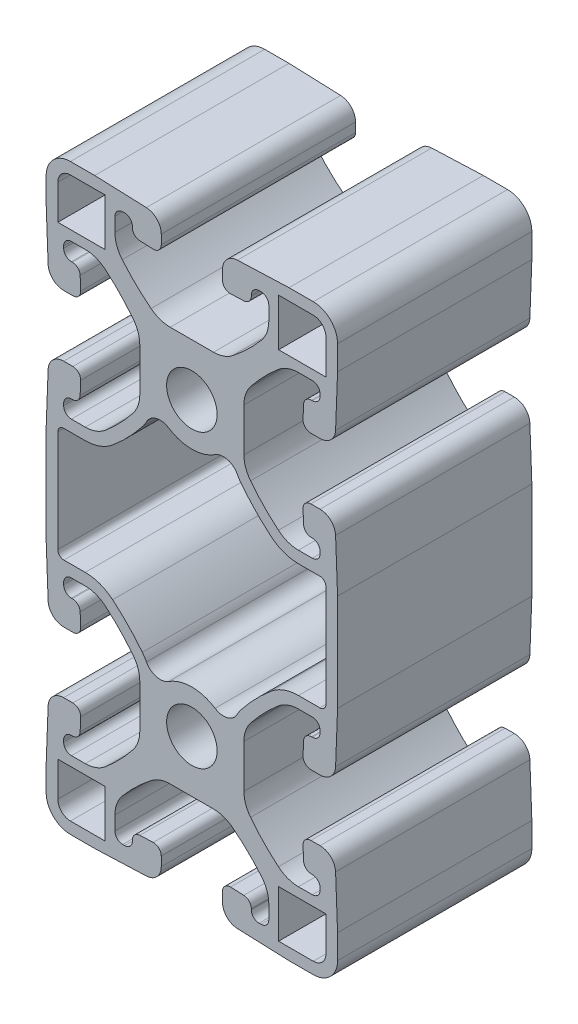
from build123d import *

# Parameters (mm, degrees)
SKETCH1_R      = 3.302
EXTRUDE1_DEPTH = 25.4


with BuildPart() as part:
    # Sketch1 → Extrude1 (new body)
    with BuildSketch(Plane.XY):
        with BuildLine():
            Line((6.8072, 35.271899209), (6.8072, 40.928100791))
            ThreePointArc((6.8072, 40.928100791), (7.029801128, 42.254656747), (7.673219048, 43.435891418))
            ThreePointArc((7.673219048, 43.435891418), (9.397406099, 45.414841404), (11.316608824, 47.205295238))
            ThreePointArc((11.316608824, 47.205295238), (12.53999053, 47.912696364), (13.931647412, 48.1584))
            Line((13.931647412, 48.1584), (15.748, 48.1584))
            ThreePointArc((15.748, 48.1584), (16.46642049, 47.86082049), (16.764, 47.1424))
            Line((16.764, 47.1424), (16.764, 46.8884))
            ThreePointArc((16.764, 46.8884), (16.46642049, 46.16997951), (15.748, 45.8724))
            Line((15.748, 45.8724), (15.618909217, 45.8724))
            ThreePointArc((15.618909217, 45.8724), (14.91441296, 45.588479929), (14.603658094, 44.895402014))
            Line((14.603658094, 44.895402014), (14.536817878, 43.155502014))
            ThreePointArc((14.536817878, 43.155502014), (14.819989072, 42.412003742), (15.552069001, 42.1005))
            Line((15.552069001, 42.1005), (16.760361628, 42.1005))
            ThreePointArc((16.760361628, 42.1005), (18.169354143, 42.668340141), (18.790863874, 44.054495972))
            Line((18.790863874, 44.054495972), (19.05, 50.8))
            Line((19.05, 50.8), (19.05, 53.975))
            ThreePointArc((19.05, 53.975), (18.12006403, 56.22006403), (15.875, 57.15))
            Line((15.875, 57.15), (12.7, 57.15))
            Line((12.7, 57.15), (5.954495972, 56.890863874))
            ThreePointArc((5.954495972, 56.890863874), (4.568340141, 56.269354143), (4.0005, 54.860361628))
            Line((4.0005, 54.860361628), (4.0005, 53.652069001))
            ThreePointArc((4.0005, 53.652069001), (4.312003742, 52.919989072), (5.055502014, 52.636817878))
            Line((5.055502014, 52.636817878), (6.795402014, 52.703658094))
            ThreePointArc((6.795402014, 52.703658094), (7.488479929, 53.01441296), (7.7724, 53.718909217))
            Line((7.7724, 53.718909217), (7.7724, 53.848))
            ThreePointArc((7.7724, 53.848), (8.06997951, 54.56642049), (8.7884, 54.864))
            Line((8.7884, 54.864), (9.0424, 54.864))
            ThreePointArc((9.0424, 54.864), (9.76082049, 54.56642049), (10.0584, 53.848))
            Line((10.0584, 53.848), (10.0584, 52.031647412))
            ThreePointArc((10.0584, 52.031647412), (9.812696364, 50.63999053), (9.105295238, 49.416608824))
            ThreePointArc((9.105295238, 49.416608824), (7.314841404, 47.497406099), (5.335891418, 45.773219048))
            ThreePointArc((5.335891418, 45.773219048), (4.154656747, 45.129801128), (2.828100791, 44.9072))
            Line((2.828100791, 44.9072), (-2.828100791, 44.9072))
            ThreePointArc((-2.828100791, 44.9072), (-4.154656747, 45.129801128), (-5.335891418, 45.773219048))
            ThreePointArc((-5.335891418, 45.773219048), (-7.314841404, 47.497406099), (-9.105295238, 49.416608824))
            ThreePointArc((-9.105295238, 49.416608824), (-9.812696364, 50.63999053), (-10.0584, 52.031647412))
            Line((-10.0584, 52.031647412), (-10.0584, 53.848))
            ThreePointArc((-10.0584, 53.848), (-9.76082049, 54.56642049), (-9.0424, 54.864))
            Line((-9.0424, 54.864), (-8.7884, 54.864))
            ThreePointArc((-8.7884, 54.864), (-8.06997951, 54.56642049), (-7.7724, 53.848))
            Line((-7.7724, 53.848), (-7.7724, 53.718909217))
            ThreePointArc((-7.7724, 53.718909217), (-7.488479929, 53.01441296), (-6.795402014, 52.703658094))
            Line((-6.795402014, 52.703658094), (-5.055502014, 52.636817878))
            ThreePointArc((-5.055502014, 52.636817878), (-4.312003742, 52.919989072), (-4.0005, 53.652069001))
            Line((-4.0005, 53.652069001), (-4.0005, 54.860361628))
            ThreePointArc((-4.0005, 54.860361628), (-4.568340141, 56.269354143), (-5.954495972, 56.890863874))
            Line((-5.954495972, 56.890863874), (-12.7, 57.15))
            Line((-12.7, 57.15), (-15.875, 57.15))
            ThreePointArc((-15.875, 57.15), (-18.12006403, 56.22006403), (-19.05, 53.975))
            Line((-19.05, 53.975), (-19.05, 50.8))
            Line((-19.05, 50.8), (-18.790863874, 44.054495972))
            ThreePointArc((-18.790863874, 44.054495972), (-18.169354143, 42.668340141), (-16.760361628, 42.1005))
            Line((-16.760361628, 42.1005), (-15.552069001, 42.1005))
            ThreePointArc((-15.552069001, 42.1005), (-14.819989072, 42.412003742), (-14.536817878, 43.155502014))
            Line((-14.536817878, 43.155502014), (-14.603658094, 44.895402014))
            ThreePointArc((-14.603658094, 44.895402014), (-14.91441296, 45.588479929), (-15.618909217, 45.8724))
            Line((-15.618909217, 45.8724), (-15.748, 45.8724))
            ThreePointArc((-15.748, 45.8724), (-16.46642049, 46.16997951), (-16.764, 46.8884))
            Line((-16.764, 46.8884), (-16.764, 47.1424))
            ThreePointArc((-16.764, 47.1424), (-16.46642049, 47.86082049), (-15.748, 48.1584))
            Line((-15.748, 48.1584), (-13.931647412, 48.1584))
            ThreePointArc((-13.931647412, 48.1584), (-12.53999053, 47.912696364), (-11.316608824, 47.205295238))
            ThreePointArc((-11.316608824, 47.205295238), (-9.397406099, 45.414841404), (-7.673219048, 43.435891418))
            ThreePointArc((-7.673219048, 43.435891418), (-7.029801128, 42.254656747), (-6.8072, 40.928100791))
            Line((-6.8072, 40.928100791), (-6.8072, 35.271899209))
            ThreePointArc((-6.8072, 35.271899209), (-7.029801128, 33.945343253), (-7.673219048, 32.764108582))
            ThreePointArc((-7.673219048, 32.764108582), (-9.397406099, 30.785158596), (-11.316608824, 28.994704762))
            ThreePointArc((-11.316608824, 28.994704762), (-12.53999053, 28.287303636), (-13.931647412, 28.0416))
            Line((-13.931647412, 28.0416), (-15.748, 28.0416))
            ThreePointArc((-15.748, 28.0416), (-16.46642049, 28.33917951), (-16.764, 29.0576))
            Line((-16.764, 29.0576), (-16.764, 29.3116))
            ThreePointArc((-16.764, 29.3116), (-16.46642049, 30.03002049), (-15.748, 30.3276))
            Line((-15.748, 30.3276), (-15.618909217, 30.3276))
            ThreePointArc((-15.618909217, 30.3276), (-14.91441296, 30.611520071), (-14.603658094, 31.304597986))
            Line((-14.603658094, 31.304597986), (-14.536817878, 33.044497986))
            ThreePointArc((-14.536817878, 33.044497986), (-14.819989072, 33.787996258), (-15.552069001, 34.0995))
            Line((-15.552069001, 34.0995), (-16.760361628, 34.0995))
            ThreePointArc((-16.760361628, 34.0995), (-18.169354143, 33.531659859), (-18.790863874, 32.145504028))
            Line((-18.790863874, 32.145504028), (-19.05, 25.4))
            Line((-19.05, 25.4), (-19.05, 12.7))
            Line((-19.05, 12.7), (-18.790863874, 5.954495972))
            ThreePointArc((-18.790863874, 5.954495972), (-18.169354143, 4.568340141), (-16.760361628, 4.0005))
            Line((-16.760361628, 4.0005), (-15.552069001, 4.0005))
            ThreePointArc((-15.552069001, 4.0005), (-14.819989072, 4.312003742), (-14.536817878, 5.055502014))
            Line((-14.536817878, 5.055502014), (-14.603658094, 6.795402014))
            ThreePointArc((-14.603658094, 6.795402014), (-14.91441296, 7.488479929), (-15.618909217, 7.7724))
            Line((-15.618909217, 7.7724), (-15.748, 7.7724))
            ThreePointArc((-15.748, 7.7724), (-16.46642049, 8.06997951), (-16.764, 8.7884))
            Line((-16.764, 8.7884), (-16.764, 9.0424))
            ThreePointArc((-16.764, 9.0424), (-16.46642049, 9.76082049), (-15.748, 10.0584))
            Line((-15.748, 10.0584), (-13.931647412, 10.0584))
            ThreePointArc((-13.931647412, 10.0584), (-12.53999053, 9.812696364), (-11.316608824, 9.105295238))
            ThreePointArc((-11.316608824, 9.105295238), (-9.397406099, 7.314841404), (-7.673219048, 5.335891418))
            ThreePointArc((-7.673219048, 5.335891418), (-7.029801128, 4.154656747), (-6.8072, 2.828100791))
            Line((-6.8072, 2.828100791), (-6.8072, -2.828100791))
            ThreePointArc((-6.8072, -2.828100791), (-7.029801128, -4.154656747), (-7.673219048, -5.335891418))
            ThreePointArc((-7.673219048, -5.335891418), (-9.397406099, -7.314841404), (-11.316608824, -9.105295238))
            ThreePointArc((-11.316608824, -9.105295238), (-12.53999053, -9.812696364), (-13.931647412, -10.0584))
            Line((-13.931647412, -10.0584), (-15.748, -10.0584))
            ThreePointArc((-15.748, -10.0584), (-16.46642049, -9.76082049), (-16.764, -9.0424))
            Line((-16.764, -9.0424), (-16.764, -8.7884))
            ThreePointArc((-16.764, -8.7884), (-16.46642049, -8.06997951), (-15.748, -7.7724))
            Line((-15.748, -7.7724), (-15.618909217, -7.7724))
            ThreePointArc((-15.618909217, -7.7724), (-14.91441296, -7.488479929), (-14.603658094, -6.795402014))
            Line((-14.603658094, -6.795402014), (-14.536817878, -5.055502014))
            ThreePointArc((-14.536817878, -5.055502014), (-14.819989072, -4.312003742), (-15.552069001, -4.0005))
            Line((-15.552069001, -4.0005), (-16.760361628, -4.0005))
            ThreePointArc((-16.760361628, -4.0005), (-18.169354143, -4.568340141), (-18.790863874, -5.954495972))
            Line((-18.790863874, -5.954495972), (-19.05, -12.7))
            Line((-19.05, -12.7), (-19.05, -15.875))
            ThreePointArc((-19.05, -15.875), (-18.12006403, -18.12006403), (-15.875, -19.05))
            Line((-15.875, -19.05), (-12.7, -19.05))
            Line((-12.7, -19.05), (-5.954495972, -18.790863874))
            ThreePointArc((-5.954495972, -18.790863874), (-4.568340141, -18.169354143), (-4.0005, -16.760361628))
            Line((-4.0005, -16.760361628), (-4.0005, -15.552069001))
            ThreePointArc((-4.0005, -15.552069001), (-4.312003742, -14.819989072), (-5.055502014, -14.536817878))
            Line((-5.055502014, -14.536817878), (-6.795402014, -14.603658094))
            ThreePointArc((-6.795402014, -14.603658094), (-7.488479929, -14.91441296), (-7.7724, -15.618909217))
            Line((-7.7724, -15.618909217), (-7.7724, -15.748))
            ThreePointArc((-7.7724, -15.748), (-8.06997951, -16.46642049), (-8.7884, -16.764))
            Line((-8.7884, -16.764), (-9.0424, -16.764))
            ThreePointArc((-9.0424, -16.764), (-9.76082049, -16.46642049), (-10.0584, -15.748))
            Line((-10.0584, -15.748), (-10.0584, -13.931647412))
            ThreePointArc((-10.0584, -13.931647412), (-9.812696364, -12.53999053), (-9.105295238, -11.316608824))
            ThreePointArc((-9.105295238, -11.316608824), (-7.314841404, -9.397406099), (-5.335891418, -7.673219048))
            ThreePointArc((-5.335891418, -7.673219048), (-4.154656747, -7.029801128), (-2.828100791, -6.8072))
            Line((-2.828100791, -6.8072), (2.828100791, -6.8072))
            ThreePointArc((2.828100791, -6.8072), (4.154656747, -7.029801128), (5.335891418, -7.673219048))
            ThreePointArc((5.335891418, -7.673219048), (7.314841404, -9.397406099), (9.105295238, -11.316608824))
            ThreePointArc((9.105295238, -11.316608824), (9.812696364, -12.53999053), (10.0584, -13.931647412))
            Line((10.0584, -13.931647412), (10.0584, -15.748))
            ThreePointArc((10.0584, -15.748), (9.76082049, -16.46642049), (9.0424, -16.764))
            Line((9.0424, -16.764), (8.7884, -16.764))
            ThreePointArc((8.7884, -16.764), (8.06997951, -16.46642049), (7.7724, -15.748))
            Line((7.7724, -15.748), (7.7724, -15.618909217))
            ThreePointArc((7.7724, -15.618909217), (7.488479929, -14.91441296), (6.795402014, -14.603658094))
            Line((6.795402014, -14.603658094), (5.055502014, -14.536817878))
            ThreePointArc((5.055502014, -14.536817878), (4.312003742, -14.819989072), (4.0005, -15.552069001))
            Line((4.0005, -15.552069001), (4.0005, -16.760361628))
            ThreePointArc((4.0005, -16.760361628), (4.568340141, -18.169354143), (5.954495972, -18.790863874))
            Line((5.954495972, -18.790863874), (12.7, -19.05))
            Line((12.7, -19.05), (15.875, -19.05))
            ThreePointArc((15.875, -19.05), (18.12006403, -18.12006403), (19.05, -15.875))
            Line((19.05, -15.875), (19.05, -12.7))
            Line((19.05, -12.7), (18.790863874, -5.954495972))
            ThreePointArc((18.790863874, -5.954495972), (18.169354143, -4.568340141), (16.760361628, -4.0005))
            Line((16.760361628, -4.0005), (15.552069001, -4.0005))
            ThreePointArc((15.552069001, -4.0005), (14.819989072, -4.312003742), (14.536817878, -5.055502014))
            Line((14.536817878, -5.055502014), (14.603658094, -6.795402014))
            ThreePointArc((14.603658094, -6.795402014), (14.91441296, -7.488479929), (15.618909217, -7.7724))
            Line((15.618909217, -7.7724), (15.748, -7.7724))
            ThreePointArc((15.748, -7.7724), (16.46642049, -8.06997951), (16.764, -8.7884))
            Line((16.764, -8.7884), (16.764, -9.0424))
            ThreePointArc((16.764, -9.0424), (16.46642049, -9.76082049), (15.748, -10.0584))
            Line((15.748, -10.0584), (13.931647412, -10.0584))
            ThreePointArc((13.931647412, -10.0584), (12.53999053, -9.812696364), (11.316608824, -9.105295238))
            ThreePointArc((11.316608824, -9.105295238), (9.397406099, -7.314841404), (7.673219048, -5.335891418))
            ThreePointArc((7.673219048, -5.335891418), (7.029801128, -4.154656747), (6.8072, -2.828100791))
            Line((6.8072, -2.828100791), (6.8072, 2.828100791))
            ThreePointArc((6.8072, 2.828100791), (7.029801128, 4.154656747), (7.673219048, 5.335891418))
            ThreePointArc((7.673219048, 5.335891418), (9.397406099, 7.314841404), (11.316608824, 9.105295238))
            ThreePointArc((11.316608824, 9.105295238), (12.53999053, 9.812696364), (13.931647412, 10.0584))
            Line((13.931647412, 10.0584), (15.748, 10.0584))
            ThreePointArc((15.748, 10.0584), (16.46642049, 9.76082049), (16.764, 9.0424))
            Line((16.764, 9.0424), (16.764, 8.7884))
            ThreePointArc((16.764, 8.7884), (16.46642049, 8.06997951), (15.748, 7.7724))
            Line((15.748, 7.7724), (15.618909217, 7.7724))
            ThreePointArc((15.618909217, 7.7724), (14.91441296, 7.488479929), (14.603658094, 6.795402014))
            Line((14.603658094, 6.795402014), (14.536817878, 5.055502014))
            ThreePointArc((14.536817878, 5.055502014), (14.819989072, 4.312003742), (15.552069001, 4.0005))
            Line((15.552069001, 4.0005), (16.760361628, 4.0005))
            ThreePointArc((16.760361628, 4.0005), (18.169354143, 4.568340141), (18.790863874, 5.954495972))
            Line((18.790863874, 5.954495972), (19.05, 12.7))
            Line((19.05, 12.7), (19.05, 25.4))
            Line((19.05, 25.4), (18.790863874, 32.145504028))
            ThreePointArc((18.790863874, 32.145504028), (18.169354143, 33.531659859), (16.760361628, 34.0995))
            Line((16.760361628, 34.0995), (15.552069001, 34.0995))
            ThreePointArc((15.552069001, 34.0995), (14.819989072, 33.787996258), (14.536817878, 33.044497986))
            Line((14.536817878, 33.044497986), (14.603658094, 31.304597986))
            ThreePointArc((14.603658094, 31.304597986), (14.91441296, 30.611520071), (15.618909217, 30.3276))
            Line((15.618909217, 30.3276), (15.748, 30.3276))
            ThreePointArc((15.748, 30.3276), (16.46642049, 30.03002049), (16.764, 29.3116))
            Line((16.764, 29.3116), (16.764, 29.0576))
            ThreePointArc((16.764, 29.0576), (16.46642049, 28.33917951), (15.748, 28.0416))
            Line((15.748, 28.0416), (13.931647412, 28.0416))
            ThreePointArc((13.931647412, 28.0416), (12.53999053, 28.287303636), (11.316608824, 28.994704762))
            ThreePointArc((11.316608824, 28.994704762), (9.397406099, 30.785158596), (7.673219048, 32.764108582))
            ThreePointArc((7.673219048, 32.764108582), (7.029801128, 33.945343253), (6.8072, 35.271899209))
        make_face()
        Circle(SKETCH1_R, mode=Mode.SUBTRACT)
        with Locations((0, 38.1)):
            Circle(SKETCH1_R, mode=Mode.SUBTRACT)
        with BuildLine():
            Line((13.946769755, 26.5049), (16.73225, 26.5049))
            ThreePointArc((16.73225, 26.5049), (17.293516008, 26.272416008), (17.526, 25.71115))
            Line((17.526, 25.71115), (17.526, 12.38885))
            ThreePointArc((17.526, 12.38885), (17.293516008, 11.827583992), (16.73225, 11.5951))
            Line((16.73225, 11.5951), (13.946769755, 11.5951))
            ThreePointArc((13.946769755, 11.5951), (12.035671421, 11.258142483), (10.35505231, 10.287907143))
            ThreePointArc((10.35505231, 10.287907143), (8.310276003, 8.382956855), (6.47397619, 6.276312903))
            ThreePointArc((6.47397619, 6.276312903), (6.185713688, 5.873090449), (5.934316511, 5.445910069))
            ThreePointArc((5.934316511, 5.445910069), (4.65067534, 4.431295394), (3.035329845, 4.691749859))
            ThreePointArc((3.035329845, 4.691749859), (0, 5.588), (-3.035329845, 4.691749859))
            ThreePointArc((-3.035329845, 4.691749859), (-4.65067534, 4.431295394), (-5.934316511, 5.445910069))
            ThreePointArc((-5.934316511, 5.445910069), (-6.185713688, 5.873090449), (-6.47397619, 6.276312903))
            ThreePointArc((-6.47397619, 6.276312903), (-8.310276003, 8.382956855), (-10.35505231, 10.287907143))
            ThreePointArc((-10.35505231, 10.287907143), (-12.035671421, 11.258142483), (-13.946769755, 11.5951))
            Line((-13.946769755, 11.5951), (-16.73225, 11.5951))
            ThreePointArc((-16.73225, 11.5951), (-17.293516008, 11.827583992), (-17.526, 12.38885))
            Line((-17.526, 12.38885), (-17.526, 25.71115))
            ThreePointArc((-17.526, 25.71115), (-17.293516008, 26.272416008), (-16.73225, 26.5049))
            Line((-16.73225, 26.5049), (-13.946769755, 26.5049))
            ThreePointArc((-13.946769755, 26.5049), (-12.035671421, 26.841857517), (-10.35505231, 27.812092857))
            ThreePointArc((-10.35505231, 27.812092857), (-8.310276003, 29.717043145), (-6.47397619, 31.823687097))
            ThreePointArc((-6.47397619, 31.823687097), (-6.185713688, 32.226909551), (-5.934316511, 32.654089931))
            ThreePointArc((-5.934316511, 32.654089931), (-4.65067534, 33.668704606), (-3.035329845, 33.408250141))
            ThreePointArc((-3.035329845, 33.408250141), (0, 32.512), (3.035329845, 33.408250141))
            ThreePointArc((3.035329845, 33.408250141), (4.65067534, 33.668704606), (5.934316511, 32.654089931))
            ThreePointArc((5.934316511, 32.654089931), (6.185713688, 32.226909551), (6.47397619, 31.823687097))
            ThreePointArc((6.47397619, 31.823687097), (8.310276003, 29.717043145), (10.35505231, 27.812092857))
            ThreePointArc((10.35505231, 27.812092857), (12.035671421, 26.841857517), (13.946769755, 26.5049))
        make_face(mode=Mode.SUBTRACT)
        with BuildLine():
            Line((-11.3411, -17.526), (-15.875, -17.526))
            ThreePointArc((-15.875, -17.526), (-17.042433296, -17.042433296), (-17.526, -15.875))
            Line((-17.526, -15.875), (-17.526, -11.3411))
            Line((-17.526, -11.3411), (-11.3411, -11.3411))
            Line((-11.3411, -11.3411), (-11.3411, -17.526))
        make_face(mode=Mode.SUBTRACT)
        with BuildLine():
            Line((11.3411, -11.3411), (17.526, -11.3411))
            Line((17.526, -11.3411), (17.526, -15.875))
            ThreePointArc((17.526, -15.875), (17.042433296, -17.042433296), (15.875, -17.526))
            Line((15.875, -17.526), (11.3411, -17.526))
            Line((11.3411, -17.526), (11.3411, -11.3411))
        make_face(mode=Mode.SUBTRACT)
        with BuildLine():
            Line((-17.526, 49.4411), (-17.526, 53.975))
            ThreePointArc((-17.526, 53.975), (-17.042433296, 55.142433296), (-15.875, 55.626))
            Line((-15.875, 55.626), (-11.3411, 55.626))
            Line((-11.3411, 55.626), (-11.3411, 49.4411))
            Line((-11.3411, 49.4411), (-17.526, 49.4411))
        make_face(mode=Mode.SUBTRACT)
        with BuildLine():
            Line((17.526, 53.975), (17.526, 49.4411))
            Line((17.526, 49.4411), (11.3411, 49.4411))
            Line((11.3411, 49.4411), (11.3411, 55.626))
            Line((11.3411, 55.626), (15.875, 55.626))
            ThreePointArc((15.875, 55.626), (17.042433296, 55.142433296), (17.526, 53.975))
        make_face(mode=Mode.SUBTRACT)
    extrude(amount=EXTRUDE1_DEPTH)


solid = part.part
